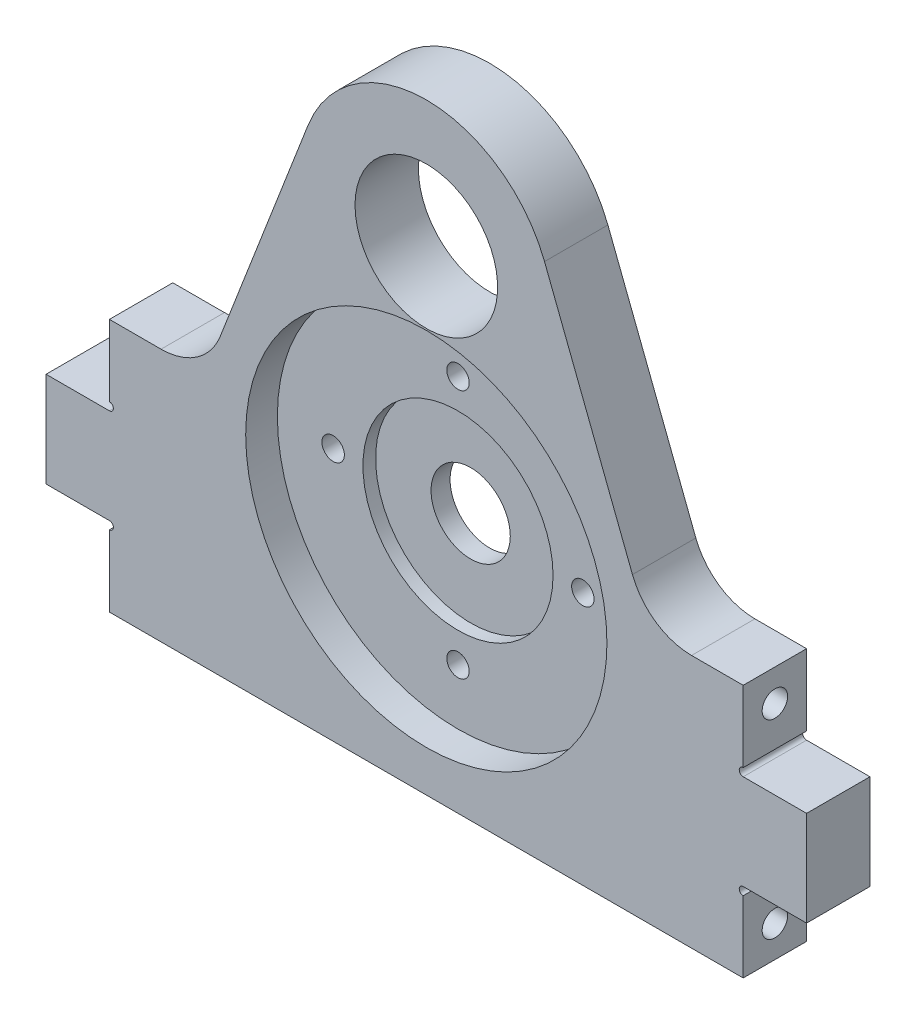
from build123d import *

# Parameters (mm, degrees)
SKETCH1_W                                      = 127
SKETCH1_H                                      = 152.4
BOSS_EXTRUDE1_DEPTH                            = 12.7
SKETCH2_R                                      = 14.2875
CUT_EXTRUDE1_DEPTH                             = 13.7
SKETCH3_R                                      = 7.9375
SKETCH3_R_2                                    = 1.016
CUT_EXTRUDE2_DEPTH                             = 13.7
SKETCH4_R                                      = 36.195
CUT_EXTRUDE3_DEPTH                             = 6.35
SKETCH5_R                                      = 19.05
CUT_EXTRUDE4_DEPTH                             = 2.54
CSK_FOR_8_FLAT_HEAD_MACHINE_SCREW1_D           = 4.4958
CSK_FOR_8_FLAT_HEAD_MACHINE_SCREW1_CSINK_D     = 8.4328
CSK_FOR_8_FLAT_HEAD_MACHINE_SCREW1_CSINK_ANGLE = 82
FILLET1_R                                      = 12.7
F_1_4_20_TAPPED_HOLE1_AT_2_COUNT               = 2
F_1_4_20_TAPPED_HOLE1_AT_2_PITCH               = 38.1
SKETCH10_W                                     = 12.7
SKETCH10_H                                     = 19.05
BOSS_EXTRUDE2_DEPTH                            = 12.7
SKETCH11_R                                     = 0.79375
CUT_EXTRUDE5_DEPTH                             = 13.7


with BuildPart() as part:
    # Sketch1 → Boss-Extrude1 (new body)
    with BuildSketch(Plane.XY):
        with Locations((0, 76.2)):
            Rectangle(SKETCH1_W, SKETCH1_H)
    extrude(amount=BOSS_EXTRUDE1_DEPTH)

    # Sketch2 → Cut-Extrude1 (cut, through all)
    with BuildSketch(Plane(origin=(0, 0, 0), x_dir=(-1, 0, 0), z_dir=(0, 0, -1))):
        with BuildLine():
            Line((44.45, 50.8), (63.5, 50.8))
            Line((63.5, 50.8), (63.5, 152.4))
            Line((63.5, 152.4), (-63.5, 152.4))
            Line((-63.5, 152.4), (-63.5, 50.8))
            Line((-63.5, 50.8), (-44.45, 50.8))
            Line((-44.45, 50.8), (-23.686198751, 104.421913036))
            ThreePointArc((-23.686198751, 104.421913036), (0, 120.65), (23.686198751, 104.421913036))
            Line((23.686198751, 104.421913036), (44.45, 50.8))
        make_face()
        with Locations((0, 95.25)):
            Circle(SKETCH2_R)
    extrude(amount=-CUT_EXTRUDE1_DEPTH, mode=Mode.SUBTRACT)

    # Sketch3 → Cut-Extrude2 (cut, through all)
    with BuildSketch(Plane.XY.offset(12.7)):
        with Locations((0, 44.45)):
            Circle(SKETCH3_R)
        with Locations((-25.019, 44.45)):
            Circle(SKETCH3_R_2)
        with Locations((25.019, 44.45)):
            Circle(SKETCH3_R_2)
        with Locations((0, 69.469)):
            Circle(SKETCH3_R_2)
        with Locations((0, 19.431)):
            Circle(SKETCH3_R_2)
    extrude(amount=-CUT_EXTRUDE2_DEPTH, mode=Mode.SUBTRACT)

    # Sketch4 → Cut-Extrude3 (cut)
    with BuildSketch(Plane.XY.offset(12.7)):
        with Locations((0, 44.45)):
            Circle(SKETCH4_R)
    extrude(amount=-CUT_EXTRUDE3_DEPTH, mode=Mode.SUBTRACT)

    # Sketch5 → Cut-Extrude4 (cut)
    with BuildSketch(Plane.XY.offset(6.35)):
        with Locations((0, 44.45)):
            Circle(SKETCH5_R)
    extrude(amount=-CUT_EXTRUDE4_DEPTH, mode=Mode.SUBTRACT)

    # CSK for #8 Flat Head Machine Screw1 (through all)
    with Locations(Plane(origin=(0, 0, 0), x_dir=(-1, 0, 0), z_dir=(0, 0, -1))):
        with Locations((0, 69.469), (25.019, 44.45), (0, 19.431), (-25.019, 44.45)):
            CounterSinkHole(CSK_FOR_8_FLAT_HEAD_MACHINE_SCREW1_D / 2, CSK_FOR_8_FLAT_HEAD_MACHINE_SCREW1_CSINK_D / 2, counter_sink_angle=CSK_FOR_8_FLAT_HEAD_MACHINE_SCREW1_CSINK_ANGLE)

    # Fillet1
    fillet1_edges = [part.edges().sort_by_distance(p)[0] for p in [
        (44.45, 50.8, 6.35),
        (-44.45, 50.8, 6.35),
    ]]
    fillet(fillet1_edges, radius=FILLET1_R)

    # Sketch8 → 1/4-20 Tapped Hole1 (revolve, cut)
    with BuildSketch(Plane(origin=(63.5, 44.45, 6.35), x_dir=(0, 0, -1), z_dir=(0, 1, 0))):
        Polygon((0, 0), (0, 18.043816902), (2.5527, 16.51), (2.5527, 0), align=None)
    f_1_4_20_tapped_hole1 = revolve(axis=Axis((69.85, 44.45, 6.35), (-1, 0, 0)), mode=Mode.SUBTRACT)

    # 1/4-20 Tapped Hole1 at 2: 1/4-20 Tapped Hole1 ×2
    with Locations(*[(0, -i * F_1_4_20_TAPPED_HOLE1_AT_2_PITCH, 0) for i in range(1, F_1_4_20_TAPPED_HOLE1_AT_2_COUNT)]):
        add(f_1_4_20_tapped_hole1, mode=Mode.SUBTRACT)

    # Sketch10 → Boss-Extrude2 (add)
    with BuildSketch(Plane(origin=(63.5, 0, 0), x_dir=(0, 0, -1), z_dir=(1, 0, 0))):
        with Locations((-6.35, 25.4)):
            Rectangle(SKETCH10_W, SKETCH10_H)
    boss_extrude2 = extrude(amount=BOSS_EXTRUDE2_DEPTH)

    # Sketch11 → Cut-Extrude5 (cut, through all)
    with BuildSketch(Plane.XY.offset(12.7)):
        with Locations((63.5, 35.71875)):
            Circle(SKETCH11_R)
        with Locations((63.5, 15.08125)):
            Circle(SKETCH11_R)
    cut_extrude5 = extrude(amount=-CUT_EXTRUDE5_DEPTH, mode=Mode.SUBTRACT)

    # Mirror1: 1/4-20 Tapped Hole1, Boss-Extrude2, Cut-Extrude5 across plane
    add(f_1_4_20_tapped_hole1.mirror(Plane(origin=(0, 0, 0), x_dir=(0, 0, 1), z_dir=(1, 0, 0))), mode=Mode.SUBTRACT)
    add(boss_extrude2.mirror(Plane(origin=(0, 0, 0), x_dir=(0, 0, 1), z_dir=(1, 0, 0))))
    add(cut_extrude5.mirror(Plane(origin=(0, 0, 0), x_dir=(0, 0, 1), z_dir=(1, 0, 0))), mode=Mode.SUBTRACT)

    # Mirror1 copy 1 sketch → Mirror1 copy 1 (revolve, cut)
    with BuildSketch(Plane(origin=(-63.5, 6.35, 6.35), x_dir=(0, 0, -1), z_dir=(0, 1, 0))):
        Polygon((0, 0), (0, -18.043816902), (2.5527, -16.51), (2.5527, 0), align=None)
    revolve(axis=Axis((-69.85, 6.35, 6.35), (-1, 0, 0)), mode=Mode.SUBTRACT)


solid = part.part
